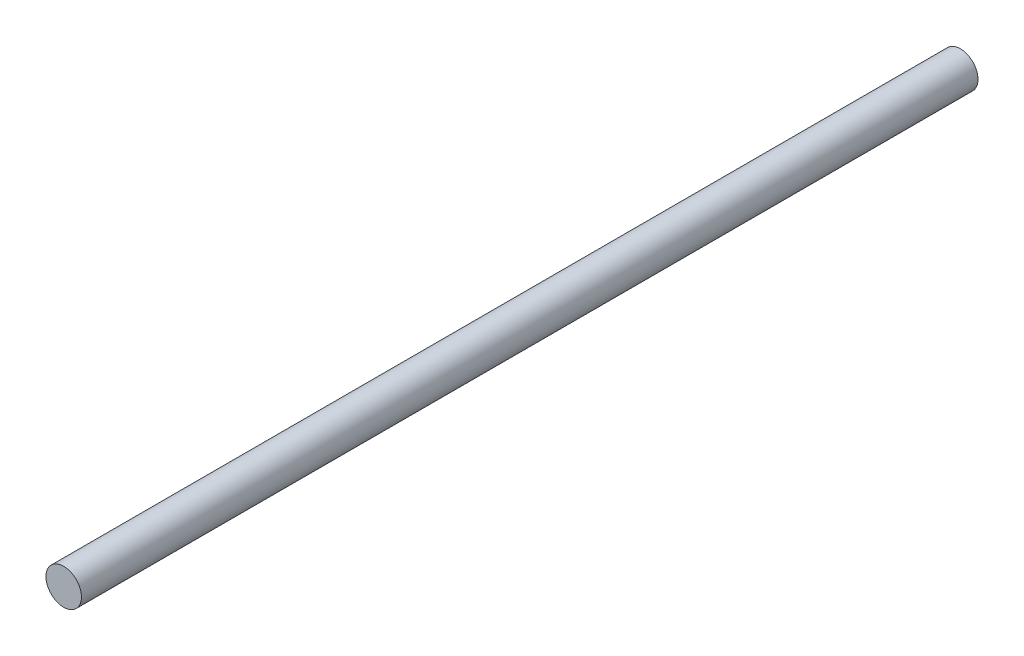
from build123d import *

# Parameters (mm, degrees)
SKETCH1_R           = 2.375
BOSS_EXTRUDE1_DEPTH = 120


with BuildPart() as part:
    # Sketch1 → Boss-Extrude1 (new body)
    with BuildSketch(Plane.XY):
        Circle(SKETCH1_R)
    extrude(amount=BOSS_EXTRUDE1_DEPTH)


solid = part.part
